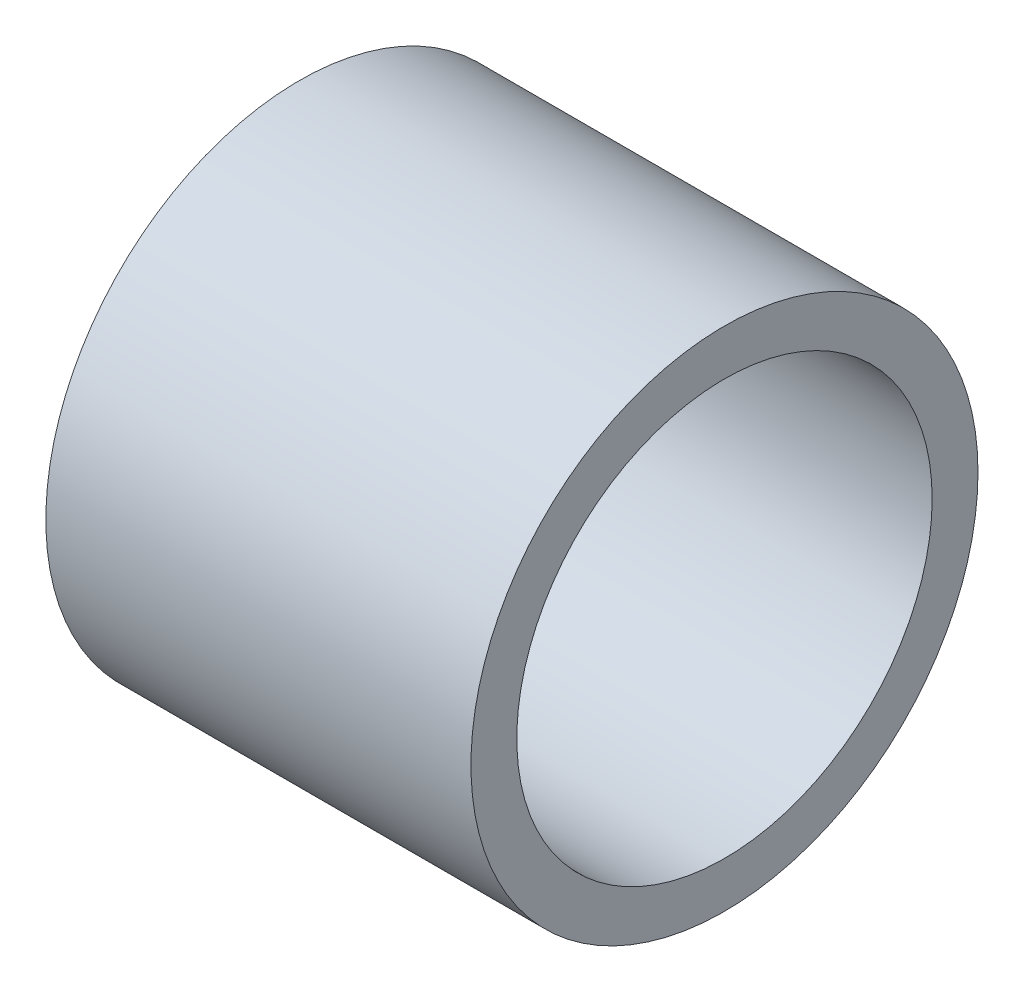
from build123d import *

# Parameters (mm, degrees)
SKETCH1_R           = 1.984375
SKETCH1_R_2         = 1.6256
BOSS_EXTRUDE1_DEPTH = 3.3274


with BuildPart() as part:
    # Sketch1 → Boss-Extrude1 (new body)
    with BuildSketch(Plane(origin=(0, 0, 0), x_dir=(0, 0, -1), z_dir=(1, 0, 0))):
        Circle(SKETCH1_R)
        Circle(SKETCH1_R_2, mode=Mode.SUBTRACT)
    extrude(amount=BOSS_EXTRUDE1_DEPTH)


solid = part.part
